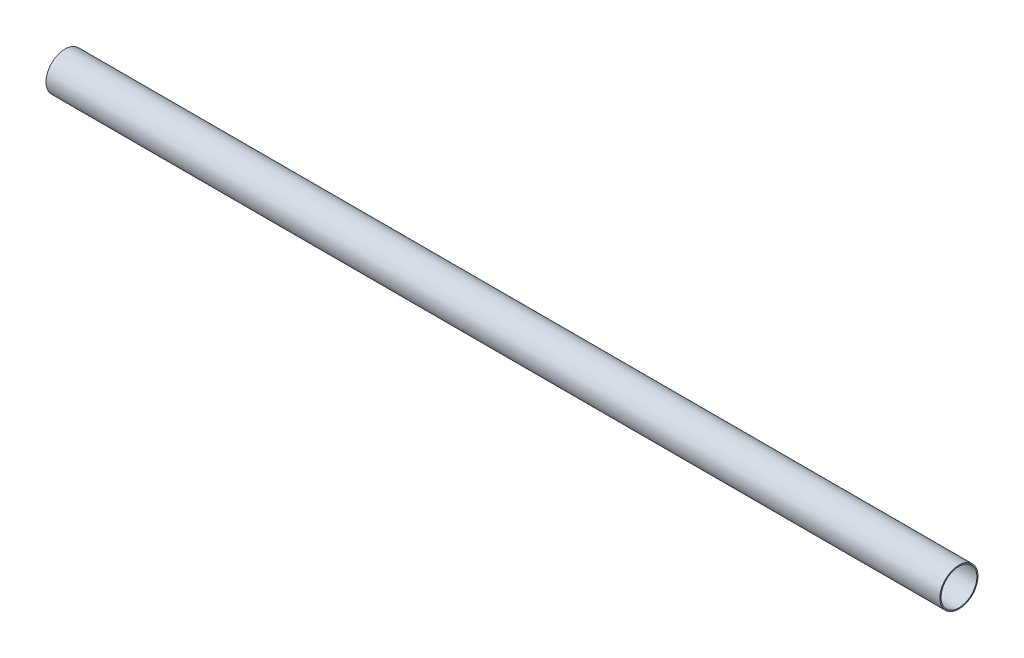
from build123d import *

# Parameters (mm, degrees)
SKETCH1_R           = 25.4
SKETCH1_R_2         = 23.9
BOSS_EXTRUDE1_DEPTH = 1192


with BuildPart() as part:
    # Sketch1 → Boss-Extrude1 (new body)
    with BuildSketch(Plane(origin=(0, 0, 0), x_dir=(0, 0, -1), z_dir=(1, 0, 0))):
        Circle(SKETCH1_R)
        Circle(SKETCH1_R_2, mode=Mode.SUBTRACT)
    extrude(amount=BOSS_EXTRUDE1_DEPTH)


solid = part.part
